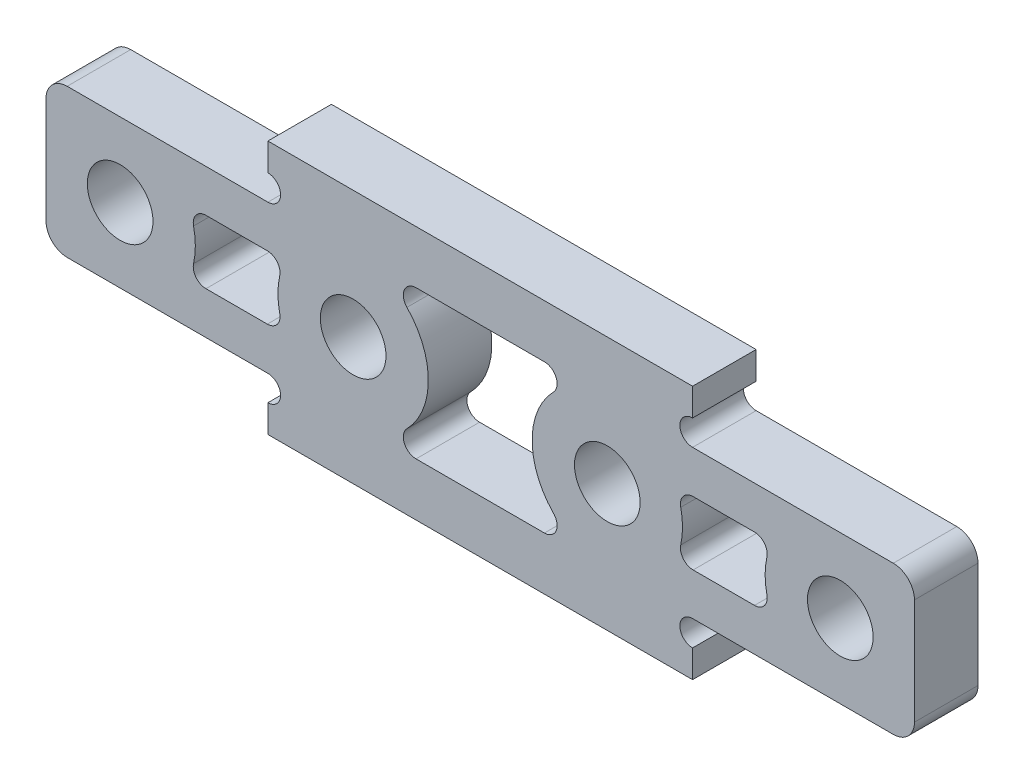
from build123d import *

# Parameters (mm, degrees)
SKETCH_1_R               = 1.55
EXTRUDE_1_DEPTH          = 1.5
SKETCH_2_R               = 0.6
CUT_EXTRUDE_1_DEPTH      = 1
CUT_EXTRUDE_1_DEPTH_BACK = 4
FILLET_1_R               = 1
CUT_EXTRUDE_2_DEPTH      = 4
FILLET_2_R               = 0.6


with BuildPart() as part:
    # 草图1 → 凸台-拉伸1 (new body, symmetric)
    with BuildSketch(Plane.XY):
        Polygon((-20.5, 3.5), (-10.025, 3.5), (-10.025, 6), (10.025, 6), (10.025, 3.5), (20.5, 3.5), (20.5, -3.5), (10.025, -3.5), (10.025, -6), (-10.025, -6), (-10.025, -3.5), (-20.5, -3.5), align=None)
        with Locations((-17, 0)):
            Circle(SKETCH_1_R, mode=Mode.SUBTRACT)
        with Locations((-6, 0)):
            Circle(SKETCH_1_R, mode=Mode.SUBTRACT)
        with Locations((6, 0)):
            Circle(SKETCH_1_R, mode=Mode.SUBTRACT)
        with Locations((17, 0)):
            Circle(SKETCH_1_R, mode=Mode.SUBTRACT)
    extrude(amount=EXTRUDE_1_DEPTH, both=True)

    # 草图2 → 切除-拉伸1 (cut, two sides)
    with BuildSketch(Plane.XY.offset(1.5)) as cut_extrude_1_sk:
        with Locations((-10.025, 4.1)):
            Circle(SKETCH_2_R)
        with Locations((-10.025, -4.1)):
            Circle(SKETCH_2_R)
        with Locations((10.025, 4.1)):
            Circle(SKETCH_2_R)
        with Locations((10.025, -4.1)):
            Circle(SKETCH_2_R)
    extrude(amount=CUT_EXTRUDE_1_DEPTH, mode=Mode.SUBTRACT)
    extrude(cut_extrude_1_sk.sketch, amount=-CUT_EXTRUDE_1_DEPTH_BACK, mode=Mode.SUBTRACT)

    # 圆角1
    fillet_1_edges = [part.edges().sort_by_distance(p)[0] for p in [
        (20.5, -3.5, 0),
        (20.5, 3.5, 0),
        (-20.5, -3.5, 0),
        (-20.5, 3.5, 0),
    ]]
    fillet(fillet_1_edges, radius=FILLET_1_R)

    # 草图4 → 切除-拉伸2 (cut, through all)
    with BuildSketch(Plane.XY.offset(1.5)):
        with BuildLine():
            Line((-13.782469891, 1.5), (-9.217530109, 1.5))
            ThreePointArc((-9.217530109, 1.5), (-9.55, 0), (-9.217530109, -1.5))
            Line((-9.217530109, -1.5), (-13.782469891, -1.5))
            ThreePointArc((-13.782469891, -1.5), (-13.45, 0), (-13.782469891, 1.5))
        make_face()
        with BuildLine():
            Line((-5.406282896, 3.5), (5.406282896, 3.5))
            ThreePointArc((5.406282896, 3.5), (2.45, 0), (5.406282896, -3.5))
            Line((5.406282896, -3.5), (-5.406282896, -3.5))
            ThreePointArc((-5.406282896, -3.5), (-2.45, 0), (-5.406282896, 3.5))
        make_face()
        with BuildLine():
            Line((13.782469891, 1.5), (9.217530109, 1.5))
            ThreePointArc((9.217530109, 1.5), (9.55, 0), (9.217530109, -1.5))
            Line((9.217530109, -1.5), (13.782469891, -1.5))
            ThreePointArc((13.782469891, -1.5), (13.45, 0), (13.782469891, 1.5))
        make_face()
    extrude(amount=-CUT_EXTRUDE_2_DEPTH, mode=Mode.SUBTRACT)

    # 圆角2
    fillet_2_edges = [part.edges().sort_by_distance(p)[0] for p in [
        (-13.782469891, -1.5, 0),
        (-13.782469891, 1.5, 0),
        (-9.217530109, 1.5, 0),
        (-9.217530109, -1.5, 0),
        (-5.406282896, -3.5, 0),
        (-5.406282896, 3.5, 0),
        (5.406282896, 3.5, 0),
        (5.406282896, -3.5, 0),
        (13.782469891, 1.5, 0),
        (13.782469891, -1.5, 0),
        (9.217530109, -1.5, 0),
        (9.217530109, 1.5, 0),
    ]]
    fillet(fillet_2_edges, radius=FILLET_2_R)


solid = part.part
